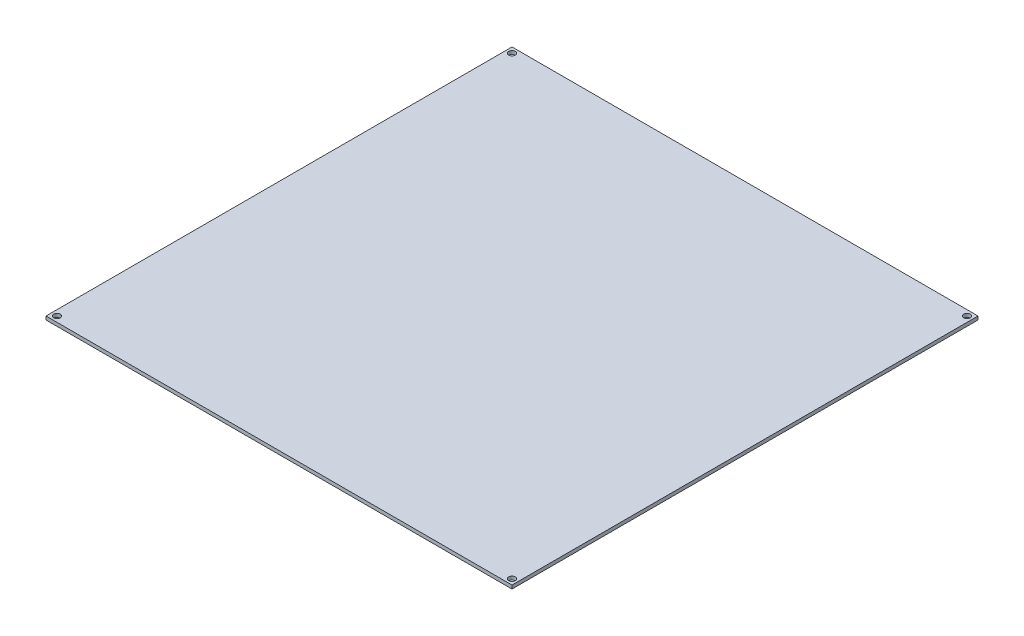
from build123d import *

# Parameters (mm, degrees)
SKETCH1_W           = 214
SKETCH1_H           = 214
SKETCH1_R           = 1.5
BOSS_EXTRUDE1_DEPTH = 1.6


with BuildPart() as part:
    # Sketch1 → Boss-Extrude1 (new body)
    with BuildSketch(Plane(origin=(0, 0, 0), x_dir=(1, 0, 0), z_dir=(0, 1, 0))):
        Rectangle(SKETCH1_W, SKETCH1_H)
        with Locations((-104.5, 104.5)):
            Circle(SKETCH1_R, mode=Mode.SUBTRACT)
        with Locations((104.5, 104.5)):
            Circle(SKETCH1_R, mode=Mode.SUBTRACT)
        with Locations((104.5, -104.5)):
            Circle(SKETCH1_R, mode=Mode.SUBTRACT)
        with Locations((-104.5, -104.5)):
            Circle(SKETCH1_R, mode=Mode.SUBTRACT)
    extrude(amount=BOSS_EXTRUDE1_DEPTH)


solid = part.part
